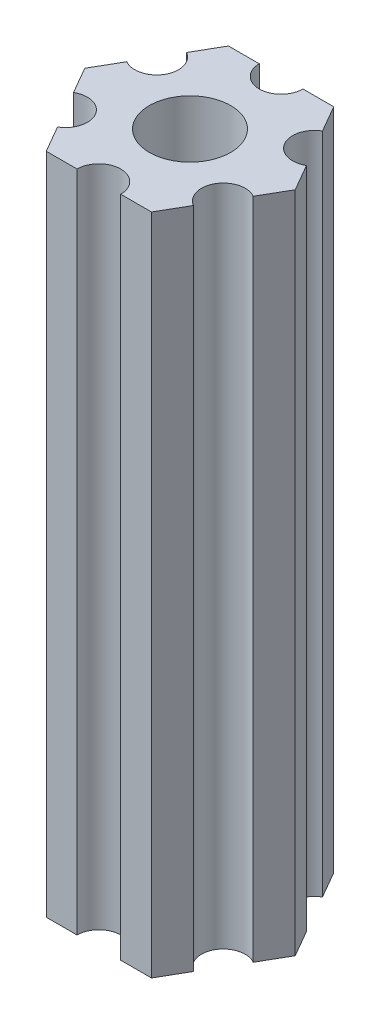
from build123d import *

# Parameters (mm, degrees)
ESBO_O1_R                = 2.79
RESSALTO_EXTRUS_O1_DEPTH = 45.5


with BuildPart() as part:
    # Esboço1 → Ressalto-extrusão1 (new body)
    with BuildSketch(Plane.XZ.offset(34.5)):
        with BuildLine():
            Line((77.062658774, 17.174038106), (78.116878365, 19))
            Line((78.116878365, 19), (77.062658774, 20.825961894))
            ThreePointArc((77.062658774, 20.825961894), (75.013620668, 21.375), (75.562658774, 23.424038106))
            Line((75.562658774, 23.424038106), (74.508439182, 25.25))
            Line((74.508439182, 25.25), (72.4, 25.25))
            ThreePointArc((72.4, 25.25), (70.9, 23.75), (69.4, 25.25))
            Line((69.4, 25.25), (67.291560818, 25.25))
            Line((67.291560818, 25.25), (66.237341226, 23.424038106))
            ThreePointArc((66.237341226, 23.424038106), (66.786379332, 21.375), (64.737341226, 20.825961894))
            Line((64.737341226, 20.825961894), (63.683121635, 19))
            Line((63.683121635, 19), (64.737341226, 17.174038106))
            ThreePointArc((64.737341226, 17.174038106), (66.786379332, 16.625), (66.237341226, 14.575961894))
            Line((66.237341226, 14.575961894), (67.291560818, 12.75))
            Line((67.291560818, 12.75), (69.4, 12.75))
            ThreePointArc((69.4, 12.75), (70.9, 14.25), (72.4, 12.75))
            Line((72.4, 12.75), (74.508439182, 12.75))
            Line((74.508439182, 12.75), (75.562658774, 14.575961894))
            ThreePointArc((75.562658774, 14.575961894), (75.013620668, 16.625), (77.062658774, 17.174038106))
        make_face()
        with Locations((70.9, 19)):
            Circle(ESBO_O1_R, mode=Mode.SUBTRACT)
    extrude(amount=-RESSALTO_EXTRUS_O1_DEPTH)


solid = part.part
